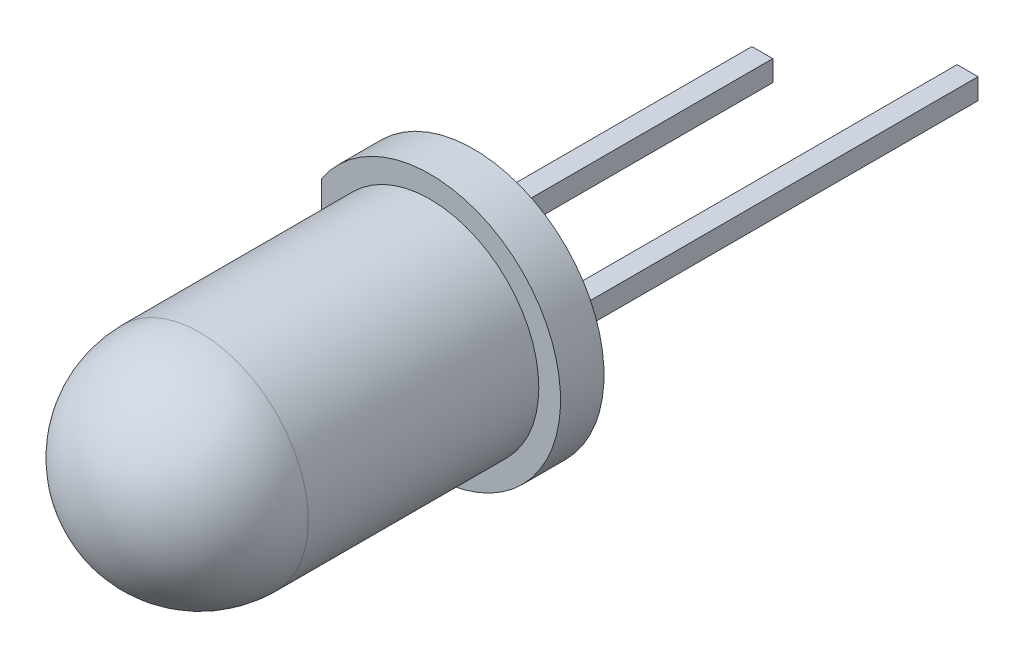
from build123d import *

# Parameters (mm, degrees)
ESBO_O1_R                  = 3
RESSALTO_EXTRUS_O1_DEPTH   = 1
CORTE_EXTRUS_O1_DEPTH      = 1
ESBO_O5_W                  = 0.48
ESBO_O5_H                  = 0.48
RESSALTO_EXTRUS_O2_DEPTH   = 8
RESSALTO_EXTRUS_O2_2_DEPTH = 8
ESBO_O6_W                  = 0.48
ESBO_O6_H                  = 0.48
RESSALTO_EXTRUS_O3_DEPTH   = 2
CORTE_EXTRUS_O2_DEPTH      = 0.24
RESSALTO_EXTRUS_O4_DEPTH   = 0.24
RESSALTO_EXTRUS_O4_2_DEPTH = 0.24
ESBO_O12_R                 = 0.2
CORTE_EXTRUS_O3_DEPTH      = 0.1


with BuildPart() as part:
    # Esboço1 → Ressalto-extrusão1 (new body)
    with BuildSketch(Plane.XY):
        Circle(ESBO_O1_R)
    extrude(amount=RESSALTO_EXTRUS_O1_DEPTH)

    # Esboço3 → Revolução1 (revolve)
    with BuildSketch(Plane(origin=(0, 0, 0), x_dir=(0, 0, -1), z_dir=(1, 0, 0))):
        with BuildLine():
            Line((-1, 0), (-8.8, 0))
            ThreePointArc((-8.8, 0), (-8.067766953, 1.767766953), (-6.3, 2.5))
            Line((-6.3, 2.5), (-1, 2.5))
            Line((-1, 2.5), (-1, 0))
        make_face()
    revolve(axis=Axis((0, 0, 1), (0, 0, 1)))

    # Esboço4 → Corte-extrusão1 (cut)
    with BuildSketch(Plane(origin=(0, 0, 0), x_dir=(-1, 0, 0), z_dir=(0, 0, -1))):
        with BuildLine():
            Line((2.5, 1.658312395), (2.5, -1.658312395))
            ThreePointArc((2.5, -1.658312395), (3, 0), (2.5, 1.658312395))
        make_face()
    extrude(amount=-CORTE_EXTRUS_O1_DEPTH, mode=Mode.SUBTRACT)

    # Esboço7 → Corte-extrusão2 (cut, symmetric)
    with BuildSketch(Plane(origin=(0, 0, 0), x_dir=(1, 0, 0), z_dir=(0, 1, 0))):
        Polygon((-1.6, 0), (-1.6, -3.5), (-1.3, -4), (1.2, -4), (0.02, -2), (-1.12, -2), (-1.12, 0), align=None)
        Polygon((1.6, 0), (1.6, -4), (1.4, -4), (0.22, -2), (1.12, -2), (1.12, 0), align=None)
    extrude(amount=CORTE_EXTRUS_O2_DEPTH, both=True, mode=Mode.SUBTRACT)


with BuildPart() as body_2:
    # Esboço5 → Ressalto-extrusão2 (new body)
    with BuildSketch(Plane(origin=(0, 0, 0), x_dir=(-1, 0, 0), z_dir=(0, 0, -1))):
        with Locations((-1.36, 0)):
            Rectangle(ESBO_O5_W, ESBO_O5_H)
    extrude(amount=RESSALTO_EXTRUS_O2_DEPTH)


with BuildPart() as body_3:
    # Esboço5 → Ressalto-extrus_o2 2 (new body)
    with BuildSketch(Plane(origin=(0, 0, 0), x_dir=(-1, 0, 0), z_dir=(0, 0, -1))):
        with Locations((1.36, 0)):
            Rectangle(ESBO_O5_W, ESBO_O5_H)
    extrude(amount=RESSALTO_EXTRUS_O2_2_DEPTH)


with BuildPart() as body_4:
    # Esboço6 → Ressalto-extrusão3 (new body)
    with BuildSketch(Plane(origin=(0, 0, -8), x_dir=(-1, 0, 0), z_dir=(0, 0, -1))):
        with Locations((-1.36, 0)):
            Rectangle(ESBO_O6_W, ESBO_O6_H)
    extrude(amount=RESSALTO_EXTRUS_O3_DEPTH)


with BuildPart() as body_5:
    # Esboço8 → Ressalto-extrusão4 (new body, symmetric)
    with BuildSketch(Plane(origin=(0, 0, 0), x_dir=(1, 0, 0), z_dir=(0, 1, 0))):
        Polygon((-1.3, -4), (1.2, -4), (0.02, -2), (-1.12, -2), (-1.12, 0), (-1.6, 0), (-1.6, -3.5), align=None)
    extrude(amount=RESSALTO_EXTRUS_O4_DEPTH, both=True)

    # Combinar2: union body 3
    add(body_3.part)

    # Esboço10 → Corte-Revolução1 (revolve, cut)
    with BuildSketch(Plane(origin=(0, 0, 0), x_dir=(1, 0, 0), z_dir=(0, 1, 0))):
        with BuildLine():
            Line((-0.05, -4), (-0.05, -3.7))
            ThreePointArc((-0.05, -3.7), (-0.341547595, -3.780754009), (-0.55, -4))
            Line((-0.55, -4), (-0.05, -4))
        make_face()
    revolve(axis=Axis((-0.05, 0, 4), (0, 0, -1)), mode=Mode.SUBTRACT)


with BuildPart() as body_6:
    # Esboço8 → Ressalto-extrus_o4 2 (new body, symmetric)
    with BuildSketch(Plane(origin=(0, 0, 0), x_dir=(1, 0, 0), z_dir=(0, 1, 0))):
        Polygon((0.22, -2), (1.4, -4), (1.6, -4), (1.6, 0), (1.12, 0), (1.12, -2), align=None)
    extrude(amount=RESSALTO_EXTRUS_O4_2_DEPTH, both=True)

    # Combinar1: union body 4, body 2
    add(body_4.part)
    add(body_2.part)


with BuildPart() as body_4_2:
    # Esboço11 → Revolução2 (revolve)
    with BuildSketch(Plane(origin=(0, 0, 0), x_dir=(1, 0, 0), z_dir=(0, 1, 0))):
        with BuildLine():
            Line((-0.55, -4), (-0.05, -4))
            Line((-0.05, -4), (-0.05, -3.7))
            ThreePointArc((-0.05, -3.7), (-0.341547595, -3.780754009), (-0.55, -4))
        make_face()
    revolve(axis=Axis((-0.05, 0, 4), (0, 0, -1)))

    # Combinar3: union body 5
    add(body_5.part)

    # Esboço12 → Corte-extrusão3 (cut)
    with BuildSketch(Plane.XY.offset(4)):
        with Locations((-0.05, 0)):
            Circle(ESBO_O12_R)
    extrude(amount=-CORTE_EXTRUS_O3_DEPTH, mode=Mode.SUBTRACT)


solid = Compound([part.part, body_6.part, body_4_2.part])
